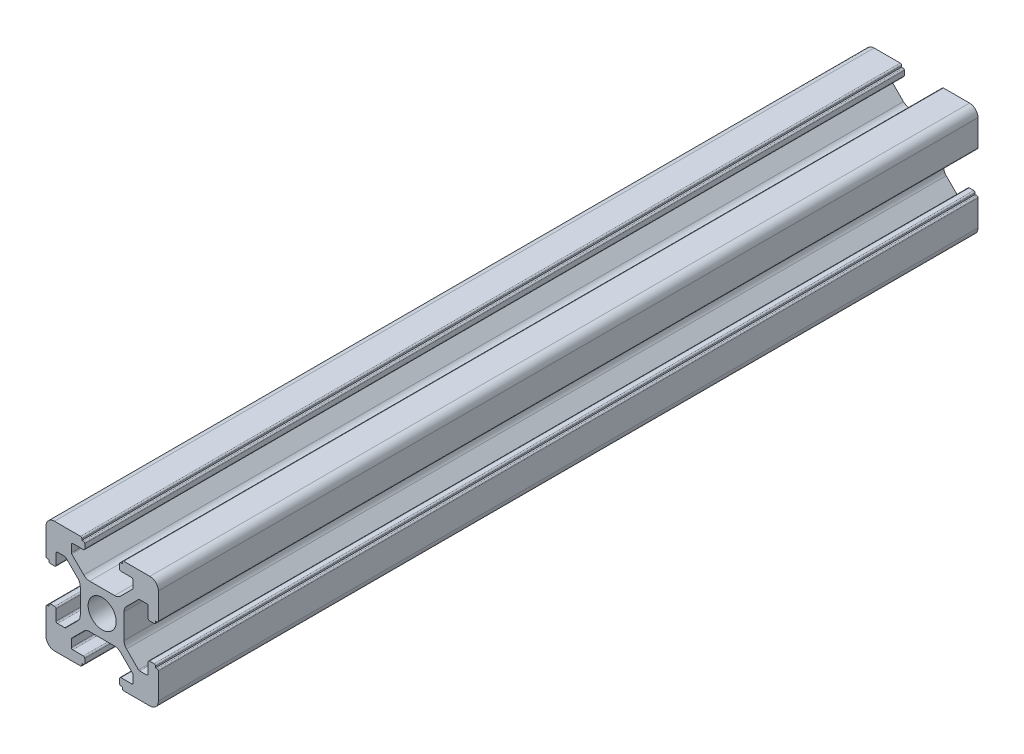
from build123d import *

# Parameters (mm, degrees)
SKETCH_1_R         = 2.5
EXTRUDE_1_DEPTH    = 1220
SKETCH1_R          = 16.771487081
CUT_EXTRUDE1_DEPTH = 1075


with BuildPart() as part:
    # 草图1 → 凸台-拉伸1 (new body)
    with BuildSketch(Plane.XY):
        with BuildLine():
            Line((-8.502261885, -10.002261885), (-3.85, -10.002261885))
            ThreePointArc((-3.85, -10.002261885), (-3.673223305, -9.929038581), (-3.6, -9.752261885))
            Line((-3.6, -9.752261885), (-3.6, -9.502261885))
            Line((-3.6, -9.502261885), (-3.35, -9.502261885))
            ThreePointArc((-3.35, -9.502261885), (-3.173223305, -9.429038581), (-3.1, -9.252261885))
            Line((-3.1, -9.252261885), (-3.1, -8.45))
            ThreePointArc((-3.1, -8.45), (-3.173223305, -8.273223305), (-3.35, -8.2))
            Line((-3.35, -8.2), (-5.25, -8.2))
            ThreePointArc((-5.25, -8.2), (-5.426776695, -8.126776695), (-5.5, -7.95))
            Line((-5.5, -7.95), (-5.5, -6.664213562))
            ThreePointArc((-5.5, -6.664213562), (-5.480969883, -6.568542704), (-5.426776695, -6.487436867))
            Line((-5.426776695, -6.487436867), (-3.278679656, -4.339339828))
            ThreePointArc((-3.278679656, -4.339339828), (-2.792044633, -4.014180701), (-2.218019485, -3.9))
            Line((-2.218019485, -3.9), (2.218019485, -3.9))
            ThreePointArc((2.218019485, -3.9), (2.792044633, -4.014180701), (3.278679656, -4.339339828))
            Line((3.278679656, -4.339339828), (5.426776695, -6.487436867))
            ThreePointArc((5.426776695, -6.487436867), (5.480969883, -6.568542704), (5.5, -6.664213562))
            Line((5.5, -6.664213562), (5.5, -7.95))
            ThreePointArc((5.5, -7.95), (5.426776695, -8.126776695), (5.25, -8.2))
            Line((5.25, -8.2), (3.35, -8.2))
            ThreePointArc((3.35, -8.2), (3.173223305, -8.273223305), (3.1, -8.45))
            Line((3.1, -8.45), (3.1, -9.252261885))
            ThreePointArc((3.1, -9.252261885), (3.173223305, -9.429038581), (3.35, -9.502261885))
            Line((3.35, -9.502261885), (3.6, -9.502261885))
            Line((3.6, -9.502261885), (3.6, -9.752261885))
            ThreePointArc((3.6, -9.752261885), (3.673223305, -9.929038581), (3.85, -10.002261885))
            Line((3.85, -10.002261885), (8.502261885, -10.002261885))
            ThreePointArc((8.502261885, -10.002261885), (9.562922057, -9.562922057), (10.002261885, -8.502261885))
            Line((10.002261885, -8.502261885), (10.002261885, -3.85))
            ThreePointArc((10.002261885, -3.85), (9.929038581, -3.673223305), (9.752261885, -3.6))
            Line((9.752261885, -3.6), (9.502261885, -3.6))
            Line((9.502261885, -3.6), (9.502261885, -3.35))
            ThreePointArc((9.502261885, -3.35), (9.429038581, -3.173223305), (9.252261885, -3.1))
            Line((9.252261885, -3.1), (8.45, -3.1))
            ThreePointArc((8.45, -3.1), (8.273223305, -3.173223305), (8.2, -3.35))
            Line((8.2, -3.35), (8.2, -5.25))
            ThreePointArc((8.2, -5.25), (8.126776695, -5.426776695), (7.95, -5.5))
            Line((7.95, -5.5), (6.664213562, -5.5))
            ThreePointArc((6.664213562, -5.5), (6.568542704, -5.480969883), (6.487436867, -5.426776695))
            Line((6.487436867, -5.426776695), (4.339339828, -3.278679656))
            ThreePointArc((4.339339828, -3.278679656), (4.014180701, -2.792044633), (3.9, -2.218019485))
            Line((3.9, -2.218019485), (3.9, 2.218019485))
            ThreePointArc((3.9, 2.218019485), (4.014180701, 2.792044633), (4.339339828, 3.278679656))
            Line((4.339339828, 3.278679656), (6.487436867, 5.426776695))
            ThreePointArc((6.487436867, 5.426776695), (6.568542704, 5.480969883), (6.664213562, 5.5))
            Line((6.664213562, 5.5), (7.95, 5.5))
            ThreePointArc((7.95, 5.5), (8.126776695, 5.426776695), (8.2, 5.25))
            Line((8.2, 5.25), (8.2, 3.35))
            ThreePointArc((8.2, 3.35), (8.273223305, 3.173223305), (8.45, 3.1))
            Line((8.45, 3.1), (9.252261885, 3.1))
            ThreePointArc((9.252261885, 3.1), (9.429038581, 3.173223305), (9.502261885, 3.35))
            Line((9.502261885, 3.35), (9.502261885, 3.6))
            Line((9.502261885, 3.6), (9.752261885, 3.6))
            ThreePointArc((9.752261885, 3.6), (9.929038581, 3.673223305), (10.002261885, 3.85))
            Line((10.002261885, 3.85), (10.002261885, 8.502261885))
            ThreePointArc((10.002261885, 8.502261885), (9.562922057, 9.562922057), (8.502261885, 10.002261885))
            Line((8.502261885, 10.002261885), (3.85, 10.002261885))
            ThreePointArc((3.85, 10.002261885), (3.673223305, 9.929038581), (3.6, 9.752261885))
            Line((3.6, 9.752261885), (3.6, 9.502261885))
            Line((3.6, 9.502261885), (3.35, 9.502261885))
            ThreePointArc((3.35, 9.502261885), (3.173223305, 9.429038581), (3.1, 9.252261885))
            Line((3.1, 9.252261885), (3.1, 8.45))
            ThreePointArc((3.1, 8.45), (3.173223305, 8.273223305), (3.35, 8.2))
            Line((3.35, 8.2), (5.25, 8.2))
            ThreePointArc((5.25, 8.2), (5.426776695, 8.126776695), (5.5, 7.95))
            Line((5.5, 7.95), (5.5, 6.664213562))
            ThreePointArc((5.5, 6.664213562), (5.480969883, 6.568542704), (5.426776695, 6.487436867))
            Line((5.426776695, 6.487436867), (3.278679656, 4.339339828))
            ThreePointArc((3.278679656, 4.339339828), (2.792044633, 4.014180701), (2.218019485, 3.9))
            Line((2.218019485, 3.9), (-2.218019485, 3.9))
            ThreePointArc((-2.218019485, 3.9), (-2.792044633, 4.014180701), (-3.278679656, 4.339339828))
            Line((-3.278679656, 4.339339828), (-5.426776695, 6.487436867))
            ThreePointArc((-5.426776695, 6.487436867), (-5.480969883, 6.568542704), (-5.5, 6.664213562))
            Line((-5.5, 6.664213562), (-5.5, 7.95))
            ThreePointArc((-5.5, 7.95), (-5.426776695, 8.126776695), (-5.25, 8.2))
            Line((-5.25, 8.2), (-3.35, 8.2))
            ThreePointArc((-3.35, 8.2), (-3.173223305, 8.273223305), (-3.1, 8.45))
            Line((-3.1, 8.45), (-3.1, 9.252261885))
            ThreePointArc((-3.1, 9.252261885), (-3.173223305, 9.429038581), (-3.35, 9.502261885))
            Line((-3.35, 9.502261885), (-3.6, 9.502261885))
            Line((-3.6, 9.502261885), (-3.6, 9.752261885))
            ThreePointArc((-3.6, 9.752261885), (-3.673223305, 9.929038581), (-3.85, 10.002261885))
            Line((-3.85, 10.002261885), (-8.502261885, 10.002261885))
            ThreePointArc((-8.502261885, 10.002261885), (-9.562922057, 9.562922057), (-10.002261885, 8.502261885))
            Line((-10.002261885, 8.502261885), (-10.002261885, 3.85))
            ThreePointArc((-10.002261885, 3.85), (-9.929038581, 3.673223305), (-9.752261885, 3.6))
            Line((-9.752261885, 3.6), (-9.502261885, 3.6))
            Line((-9.502261885, 3.6), (-9.502261885, 3.35))
            ThreePointArc((-9.502261885, 3.35), (-9.429038581, 3.173223305), (-9.252261885, 3.1))
            Line((-9.252261885, 3.1), (-8.45, 3.1))
            ThreePointArc((-8.45, 3.1), (-8.273223305, 3.173223305), (-8.2, 3.35))
            Line((-8.2, 3.35), (-8.2, 5.25))
            ThreePointArc((-8.2, 5.25), (-8.126776695, 5.426776695), (-7.95, 5.5))
            Line((-7.95, 5.5), (-6.664213562, 5.5))
            ThreePointArc((-6.664213562, 5.5), (-6.568542704, 5.480969883), (-6.487436867, 5.426776695))
            Line((-6.487436867, 5.426776695), (-4.339339828, 3.278679656))
            ThreePointArc((-4.339339828, 3.278679656), (-4.014180701, 2.792044633), (-3.9, 2.218019485))
            Line((-3.9, 2.218019485), (-3.9, -2.218019485))
            ThreePointArc((-3.9, -2.218019485), (-4.014180701, -2.792044633), (-4.339339828, -3.278679656))
            Line((-4.339339828, -3.278679656), (-6.487436867, -5.426776695))
            ThreePointArc((-6.487436867, -5.426776695), (-6.568542704, -5.480969883), (-6.664213562, -5.5))
            Line((-6.664213562, -5.5), (-7.95, -5.5))
            ThreePointArc((-7.95, -5.5), (-8.126776695, -5.426776695), (-8.2, -5.25))
            Line((-8.2, -5.25), (-8.2, -3.35))
            ThreePointArc((-8.2, -3.35), (-8.273223305, -3.173223305), (-8.45, -3.1))
            Line((-8.45, -3.1), (-9.252261885, -3.1))
            ThreePointArc((-9.252261885, -3.1), (-9.429038581, -3.173223305), (-9.502261885, -3.35))
            Line((-9.502261885, -3.35), (-9.502261885, -3.6))
            Line((-9.502261885, -3.6), (-9.752261885, -3.6))
            ThreePointArc((-9.752261885, -3.6), (-9.929038581, -3.673223305), (-10.002261885, -3.85))
            Line((-10.002261885, -3.85), (-10.002261885, -8.502261885))
            ThreePointArc((-10.002261885, -8.502261885), (-9.562922057, -9.562922057), (-8.502261885, -10.002261885))
        make_face()
        Circle(SKETCH_1_R, mode=Mode.SUBTRACT)
    extrude(amount=EXTRUDE_1_DEPTH)

    # Sketch1 → Cut-Extrude1 (cut, through all)
    with BuildSketch(Plane.XY.offset(1074)):
        Circle(SKETCH1_R)
    extrude(amount=-CUT_EXTRUDE1_DEPTH, mode=Mode.SUBTRACT)


solid = part.part
